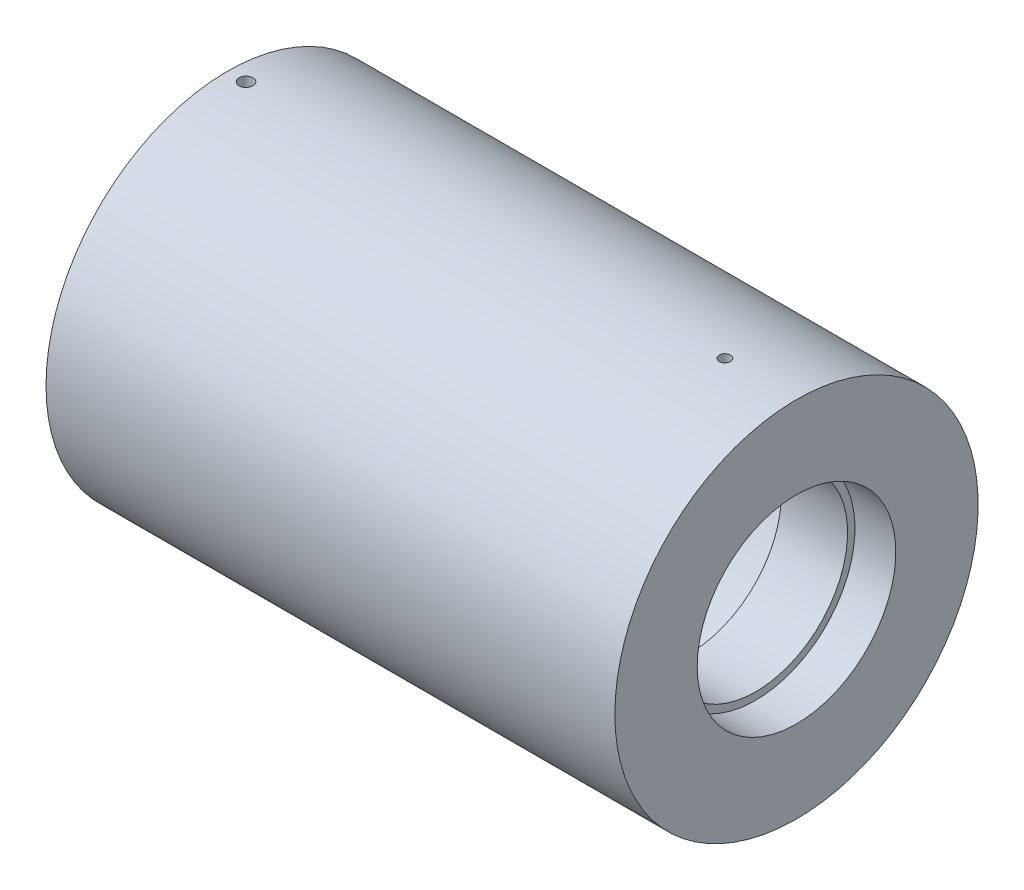
from build123d import *

# Parameters (mm, degrees)
KREISMUSTER1_COUNT                 = 2
M8_GEWINDEBOHRUNG1_REACH           = 179.8
M8_GEWINDEBOHRUNG1_BORE_R          = 3.4
M8_GEWINDEBOHRUNG1_ON_FACE_2_REACH = 179.8
M8_GEWINDEBOHRUNG1_BORE_2_R        = 3.4


with BuildPart() as part:
    # Skizze1 → Rotation1 (revolve)
    with BuildSketch(Plane.XY, mode=Mode.PRIVATE) as rotation1_sk:
        with BuildLine():
            Line((0, 88.9), (278.4, 88.9))
            Line((278.4, 88.9), (278.4, 48.6))
            Line((278.4, 48.6), (258.4, 48.6))
            Line((258.4, 48.6), (258.4, 45))
            Line((258.4, 45), (226, 45))
            Line((226, 45), (226, 66.5))
            ThreePointArc((226, 66.5), (225.707106781, 67.207106781), (225, 67.5))
            Line((225, 67.5), (0, 67.5))
            Line((0, 67.5), (0, 88.9))
        make_face()
    revolve(rotation1_sk.sketch.rotate(Axis((0, 0, 0), (1, 0, 0)), 90), axis=Axis((0, 0, 0), (1, 0, 0)))  # turned: the seam where the file's is

    # Skizze6 → Schnitt-Rotation1 (revolve, cut)
    with BuildSketch(Plane.XY, mode=Mode.PRIVATE) as schnitt_rotation1_sk:
        Polygon((243.4, 88.9), (246.15, 88.9), (246.15, 69.3), (243.4, 67.647633298), align=None)
    schnitt_rotation1 = revolve(schnitt_rotation1_sk.sketch.rotate(Axis((243.4, 88.9, 0), (0, -1, 0)), 90), axis=Axis((243.4, 88.9, 0), (0, -1, 0)), mode=Mode.SUBTRACT)  # turned: the seam where the file's is

    # Kreismuster1: Schnitt-Rotation1 ×2 about axis
    kreismuster1_axis = Axis((0, 0, 0), (-1, 0, 0))
    for i in range(1, KREISMUSTER1_COUNT):
        add(schnitt_rotation1.rotate(kreismuster1_axis, i * 360 / KREISMUSTER1_COUNT), mode=Mode.SUBTRACT)

    # M8 Gewindebohrung1 bore (on position points) → M8 Gewindebohrung1 (cut, up to next)
    with BuildSketch(Plane(origin=(9, 88.9, 0), x_dir=(0, 0, 1), z_dir=(0, 1, 0)), mode=Mode.PRIVATE) as m8_gewindebohrung1_sk1:
        Circle(M8_GEWINDEBOHRUNG1_BORE_R)
    m8_gewindebohrung1_tool1 = extrude(m8_gewindebohrung1_sk1.sketch, amount=-M8_GEWINDEBOHRUNG1_REACH, mode=Mode.PRIVATE) & part.part
    add(m8_gewindebohrung1_tool1.solids().sort_by_distance((9, 88.9, 0))[0], mode=Mode.SUBTRACT)

    # M8 Gewindebohrung1 bore 2 (on position points) → M8 Gewindebohrung1 on face 2 (cut, up to next)
    with BuildSketch(Plane(origin=(9, 0, -88.9), x_dir=(-1, 0, 0), z_dir=(0, 0, -1)), mode=Mode.PRIVATE) as m8_gewindebohrung1_on_face_2_sk1:
        Circle(M8_GEWINDEBOHRUNG1_BORE_2_R)
    m8_gewindebohrung1_on_face_2_tool1 = extrude(m8_gewindebohrung1_on_face_2_sk1.sketch, amount=-M8_GEWINDEBOHRUNG1_ON_FACE_2_REACH, mode=Mode.PRIVATE) & part.part
    add(m8_gewindebohrung1_on_face_2_tool1.solids().sort_by_distance((9, 0, -88.9))[0], mode=Mode.SUBTRACT)


solid = part.part
